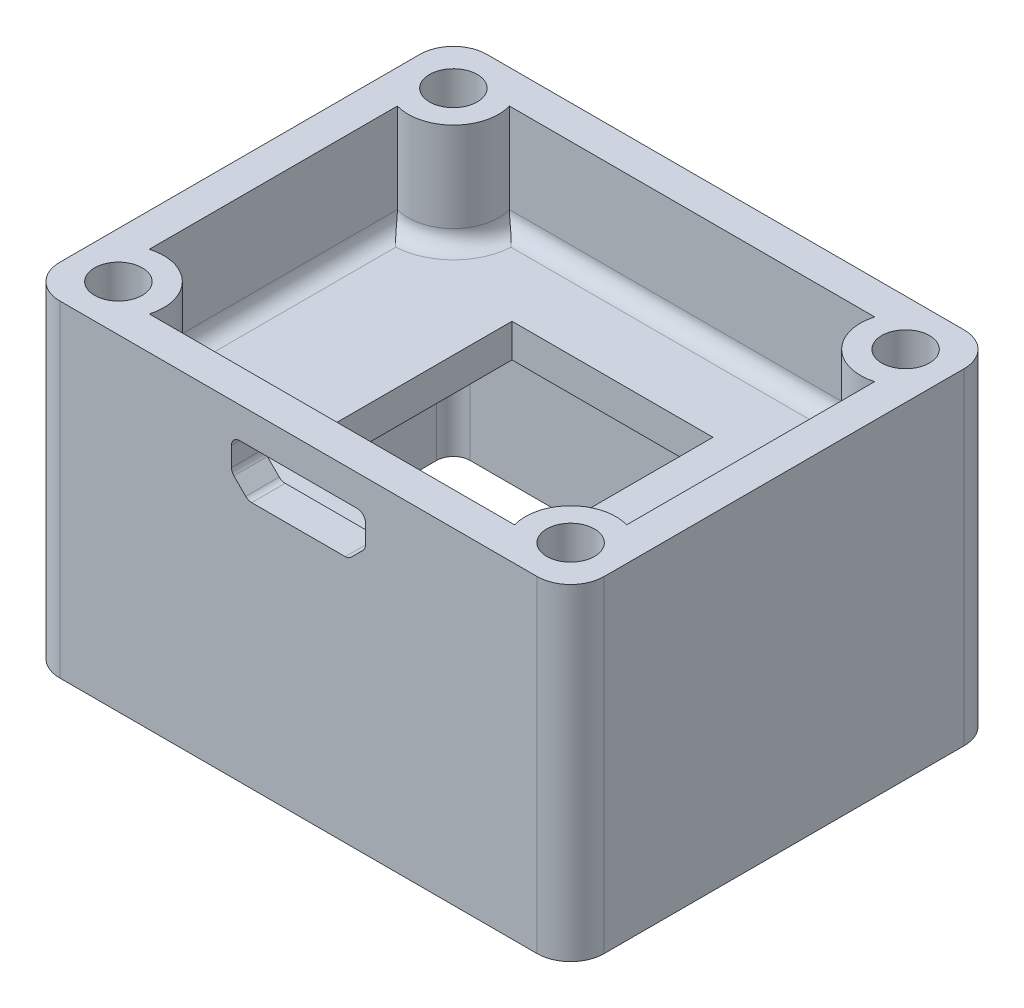
from build123d import *

# Parameters (mm, degrees)
SKETCH_1_W          = 32.5
SKETCH_1_H          = 25.5
SKETCH_1_W_2        = 28.5
SKETCH_1_H_2        = 21.5
EXTRUDE_1_DEPTH     = 13.2
SKETCH_2_W          = 28.5
SKETCH_2_H          = 21.5
SKETCH_2_W_2        = 12
SKETCH_2_H_2        = 12
EXTRUDE_2_DEPTH     = 2
EXTRUDE_3_DEPTH     = 6.3
EXTRUDE_4_REACH     = 21.5
SKETCH_6_R          = 2.7
SKETCH_7_R          = 1.425
CUT_EXTRUDE_3_DEPTH = 5.5
SKETCH_10_W         = 15.8
SKETCH_10_H         = 15.8
SKETCH_10_W_2       = 14.2
SKETCH_10_H_2       = 14.2
EXTRUDE_5_DEPTH     = 0.8
CUT_EXTRUDE_5_DEPTH = 3
FILLET_6_R          = 0.5
FILLET_3_R          = 0.95
FILLET_1_R          = 2
FILLET_2_R          = 1


with BuildPart() as part:
    # 草图1 → 凸台-拉伸1 (new body)
    with BuildSketch(Plane(origin=(0, 0, 0), x_dir=(1, 0, 0), z_dir=(0, 1, 0))):
        Rectangle(SKETCH_1_W, SKETCH_1_H)
        Rectangle(SKETCH_1_W_2, SKETCH_1_H_2, mode=Mode.SUBTRACT)
    extrude(amount=EXTRUDE_1_DEPTH)

    # 草图2 → 凸台-拉伸2 (add)
    with BuildSketch(Plane(origin=(0, 13.2, 0), x_dir=(1, 0, 0), z_dir=(0, 1, 0))):
        Rectangle(SKETCH_2_W, SKETCH_2_H)
        Rectangle(SKETCH_2_W_2, SKETCH_2_H_2, mode=Mode.SUBTRACT)
    extrude(amount=-EXTRUDE_2_DEPTH)

    # 草图3 → 凸台-拉伸3 (add)
    with BuildSketch(Plane(origin=(0, 13.2, 0), x_dir=(1, 0, 0), z_dir=(0, 1, 0))):
        Polygon((-16.25, -12.75), (-16.25, 12.75), (16.25, 12.75), (16.25, -0.040360215), (16.25, -12.75), align=None)
        Polygon((14.25, 0.013681835), (14.25, 10.75), (-14.25, 10.75), (-14.25, -10.75), (14.25, -10.75), align=None, mode=Mode.SUBTRACT)
    extrude(amount=EXTRUDE_3_DEPTH)

    # 草图6 → 凸台-拉伸4 (add, up to next)
    with BuildSketch(Plane(origin=(0, 19.5, 0), x_dir=(1, 0, 0), z_dir=(0, 1, 0)), mode=Mode.PRIVATE) as extrude_4_sk1:
        with Locations((13.5, 10)):
            Circle(SKETCH_6_R)
    extrude_4_tool1 = extrude(extrude_4_sk1.sketch, amount=-EXTRUDE_4_REACH, mode=Mode.PRIVATE) - part.part
    add(extrude_4_tool1.solids().sort_by_distance((13.5, 19.5, -10))[0])
    # 草图6 → 凸台-拉伸4 (add, up to next)
    with BuildSketch(Plane(origin=(0, 19.5, 0), x_dir=(1, 0, 0), z_dir=(0, 1, 0)), mode=Mode.PRIVATE) as extrude_4_sk2:
        with Locations((13.5, -10)):
            Circle(SKETCH_6_R)
    extrude_4_tool2 = extrude(extrude_4_sk2.sketch, amount=-EXTRUDE_4_REACH, mode=Mode.PRIVATE) - part.part
    add(extrude_4_tool2.solids().sort_by_distance((13.5, 19.5, 10))[0])
    # 草图6 → 凸台-拉伸4 (add, up to next)
    with BuildSketch(Plane(origin=(0, 19.5, 0), x_dir=(1, 0, 0), z_dir=(0, 1, 0)), mode=Mode.PRIVATE) as extrude_4_sk3:
        with Locations((-13.5, -10)):
            Circle(SKETCH_6_R)
    extrude_4_tool3 = extrude(extrude_4_sk3.sketch, amount=-EXTRUDE_4_REACH, mode=Mode.PRIVATE) - part.part
    add(extrude_4_tool3.solids().sort_by_distance((-13.5, 19.5, 10))[0])
    # 草图6 → 凸台-拉伸4 (add, up to next)
    with BuildSketch(Plane(origin=(0, 19.5, 0), x_dir=(1, 0, 0), z_dir=(0, 1, 0)), mode=Mode.PRIVATE) as extrude_4_sk4:
        with Locations((-13.5, 10)):
            Circle(SKETCH_6_R)
    extrude_4_tool4 = extrude(extrude_4_sk4.sketch, amount=-EXTRUDE_4_REACH, mode=Mode.PRIVATE) - part.part
    add(extrude_4_tool4.solids().sort_by_distance((-13.5, 19.5, -10))[0])

    # 草图7 → 切除-拉伸3 (cut)
    with BuildSketch(Plane(origin=(0, 19.5, 0), x_dir=(1, 0, 0), z_dir=(0, 1, 0))):
        with Locations((13.5, 10)):
            Circle(SKETCH_7_R)
        with Locations((13.5, -10)):
            Circle(SKETCH_7_R)
        with Locations((-13.5, -10)):
            Circle(SKETCH_7_R)
        with Locations((-13.5, 10)):
            Circle(SKETCH_7_R)
    extrude(amount=-CUT_EXTRUDE_3_DEPTH, mode=Mode.SUBTRACT)

    # 草图10 → 凸台-拉伸5 (add)
    with BuildSketch(Plane.XZ.offset(-11.2)):
        Rectangle(SKETCH_10_W, SKETCH_10_H)
        Rectangle(SKETCH_10_W_2, SKETCH_10_H_2, mode=Mode.SUBTRACT)
    extrude(amount=EXTRUDE_5_DEPTH)

    # 草图11 → 切除-拉伸5 (cut)
    with BuildSketch(Plane.XY.offset(12.75)):
        Polygon((-4, 17.65), (4, 17.65), (4, 15.8), (3, 14.8), (-3, 14.8), (-4, 15.8), align=None)
    extrude(amount=-CUT_EXTRUDE_5_DEPTH, mode=Mode.SUBTRACT)

    # 圆角6
    fillet_6_edges = [part.edges().sort_by_distance(p)[0] for p in [
        (4, 17.65, 11.75),
        (4, 15.8, 11.75),
        (3, 14.8, 11.75),
        (-3, 14.8, 11.75),
        (-4, 15.8, 11.75),
        (-4, 17.65, 11.75),
    ]]
    fillet(fillet_6_edges, radius=FILLET_6_R)

    # 圆角3
    fillet_3_edges = [part.edges().sort_by_distance(p)[0] for p in [
        (0, 13.2, 10.75),
        (-11.590811691, 13.2, 8.090811691),
        (-14.25, 13.2, 0),
        (-11.590811691, 13.2, -8.090811691),
        (0, 13.2, -10.75),
        (11.590811691, 13.2, -8.090811691),
        (14.25, 13.2, 0),
        (11.590811691, 13.2, 8.090811691),
    ]]
    fillet(fillet_3_edges, radius=FILLET_3_R)

    # 圆角1
    fillet_1_edges = [part.edges().sort_by_distance(p)[0] for p in [
        (16.25, 9.75, 12.75),
        (-16.25, 9.75, 12.75),
        (-16.25, 9.75, -12.75),
        (16.25, 9.75, -12.75),
    ]]
    fillet(fillet_1_edges, radius=FILLET_1_R)

    # 圆角2
    fillet_2_edges = [part.edges().sort_by_distance(p)[0] for p in [
        (-14.25, 5.6, 10.75),
        (14.25, 5.6, 10.75),
        (-14.25, 5.6, -10.75),
        (14.25, 5.6, -10.75),
    ]]
    fillet(fillet_2_edges, radius=FILLET_2_R)


solid = part.part
